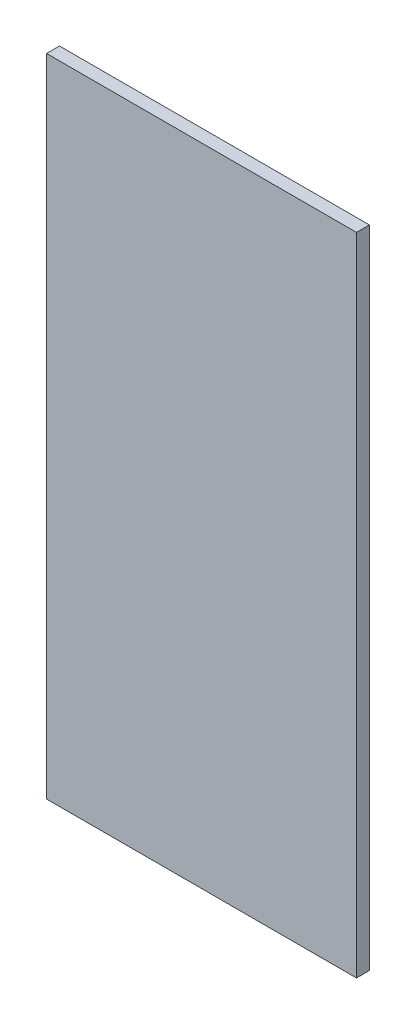
from build123d import *

# Parameters (mm, degrees)
CROQUIS2_W              = 152.4
CROQUIS2_H              = 317.5
SALIENTE_EXTRUIR1_DEPTH = 6.35


with BuildPart() as part:
    # Croquis2 → Saliente-Extruir1 (new body)
    with BuildSketch(Plane.XY):
        Rectangle(CROQUIS2_W, CROQUIS2_H)
    extrude(amount=SALIENTE_EXTRUIR1_DEPTH)


solid = part.part
